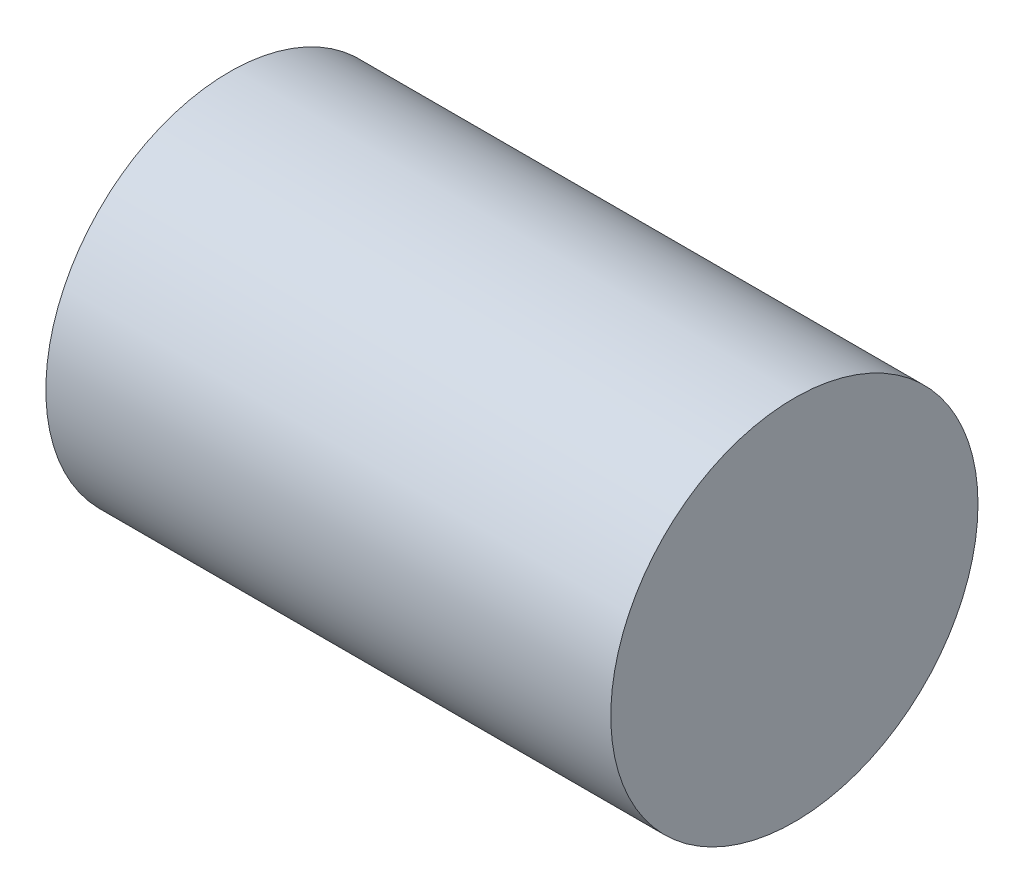
from build123d import *

# Parameters (mm, degrees)
SKETCH1_R           = 19.5
BOSS_EXTRUDE1_DEPTH = 60


with BuildPart() as part:
    # Sketch1 → Boss-Extrude1 (new body)
    with BuildSketch(Plane(origin=(0, 0, 0), x_dir=(0, 0, -1), z_dir=(1, 0, 0))):
        Circle(SKETCH1_R)
    extrude(amount=BOSS_EXTRUDE1_DEPTH)


solid = part.part
